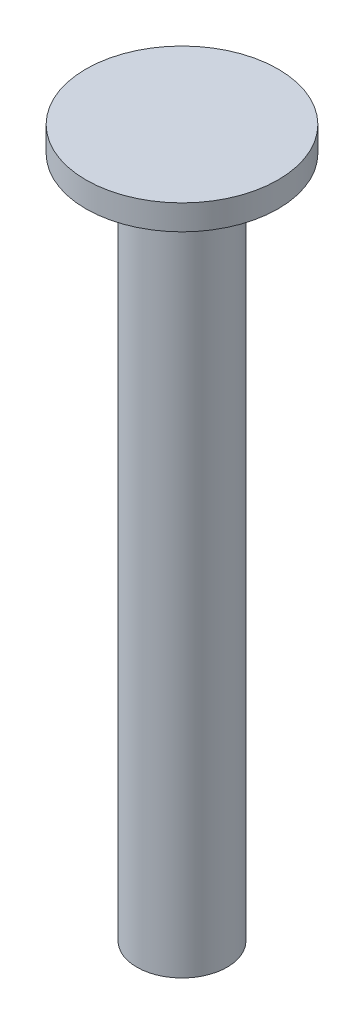
from build123d import *

# Parameters (mm, degrees)
SKETCH2_R           = 1.14411506
BOSS_EXTRUDE1_DEPTH = 17.27
SKETCH3_R           = 2.432603599
BOSS_EXTRUDE2_DEPTH = 0.635


with BuildPart() as part:
    # Sketch2 → Boss-Extrude1 (new body)
    with BuildSketch(Plane(origin=(0, -47.666395073, 0), x_dir=(1, 0, 0), z_dir=(0, 1, 0))):
        with Locations((8.115169221, -1.319009852)):
            Circle(SKETCH2_R)
    extrude(amount=-BOSS_EXTRUDE1_DEPTH)

    # Sketch3 → Boss-Extrude2 (add)
    with BuildSketch(Plane(origin=(0, -47.666395073, 0), x_dir=(1, 0, 0), z_dir=(0, 1, 0))):
        with Locations((8.115169221, -1.319009852)):
            Circle(SKETCH3_R)
    extrude(amount=BOSS_EXTRUDE2_DEPTH)


solid = part.part
